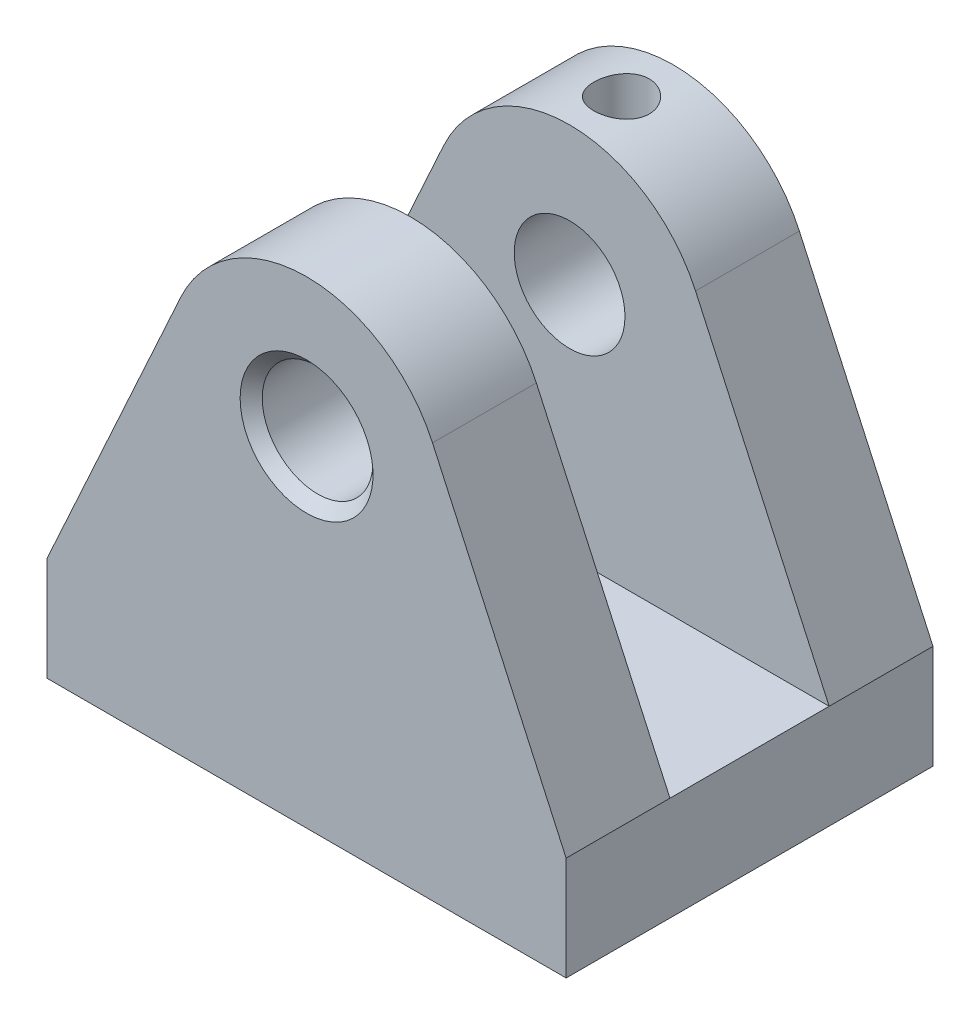
from build123d import *

# Parameters (mm, degrees)
P_IDAT_VYSUNUT_M1_DEPTH       = 15
SKICA4_W                      = 75
SKICA4_H                      = 14.99699372
P_IDAT_VYSUNUT_M2_DEPTH       = 11.5
SKICA6_R                      = 8
ODEBRAT_VYSUNUT_M1_DEPTH      = 54
ODEBRAT_VYSUNUT_M2_REACH      = 71
ODEBRAT_VYSUNUT_M2_END_RADIUS = 8
SKICA7_R                      = 4
ZKOSEN_1_SIZE                 = 1.6


with BuildPart() as part:
    # Skica1 → Přidat vysunutím1 (new body)
    with BuildSketch(Plane.XY):
        with BuildLine():
            Line((-37.5, 0), (-37.5, 14.99699372))
            Line((-37.5, 14.99699372), (-18.194945848, 57.300242817))
            ThreePointArc((-18.194945848, 57.300242817), (0, 68.99699372), (18.194945848, 57.300242817))
            Line((18.194945848, 57.300242817), (37.5, 14.99699372))
            Line((37.5, 14.99699372), (37.5, 0))
            Line((37.5, 0), (-37.5, 0))
        make_face()
    extrude(amount=P_IDAT_VYSUNUT_M1_DEPTH)

    # Skica4 → Přidat vysunutím2 (add)
    with BuildSketch(Plane(origin=(0, 0, 0), x_dir=(-1, 0, 0), z_dir=(0, 0, -1))):
        with Locations((0, 7.49849686)):
            Rectangle(SKICA4_W, SKICA4_H)
    extrude(amount=P_IDAT_VYSUNUT_M2_DEPTH)

    # Zrcadlit1: part across plane


with BuildPart() as part_1:
    add(part.part)
    add(part.part.mirror(Plane.XY.offset(-11.5)))

    # Skica6 → Odebrat vysunutím1 (cut, through all)
    with BuildSketch(Plane.XY.offset(15)):
        with Locations((0, 49)):
            Circle(SKICA6_R)
    extrude(amount=-ODEBRAT_VYSUNUT_M1_DEPTH, mode=Mode.SUBTRACT)

    # Odebrat vysunutím2: up to this cylinder (the profile starts outside it)
    odebrat_vysunut_m2_end = Plane(origin=(0, 49, -30.5), z_dir=(0, 0, 1)) * Cylinder(ODEBRAT_VYSUNUT_M2_END_RADIUS, 159, mode=Mode.PRIVATE)
    # Skica7 → Odebrat vysunutím2 (cut, up to the surface)
    with BuildSketch(Plane(origin=(0, 69, 0), x_dir=(1, 0, 0), z_dir=(0, 1, 0)), mode=Mode.PRIVATE) as odebrat_vysunut_m2_sk1:
        with Locations(Location((0, 30.5, 0), (0, 0, 270))):  # turned: the seam where the file's is
            Circle(SKICA7_R)
    odebrat_vysunut_m2_tool1 = extrude(odebrat_vysunut_m2_sk1.sketch, amount=-ODEBRAT_VYSUNUT_M2_REACH, mode=Mode.PRIVATE) - odebrat_vysunut_m2_end
    add(odebrat_vysunut_m2_tool1.solids().sort_by_distance((0, 69, -30.5))[0], mode=Mode.SUBTRACT)

    # Zkosení1
    zkosen_1_edges = [part_1.edges().sort_by_distance(p)[0] for p in [
        (-8, 49, -38),
        (-8, 49, 15),
    ]]
    chamfer(zkosen_1_edges, length=ZKOSEN_1_SIZE)


solid = part_1.part
